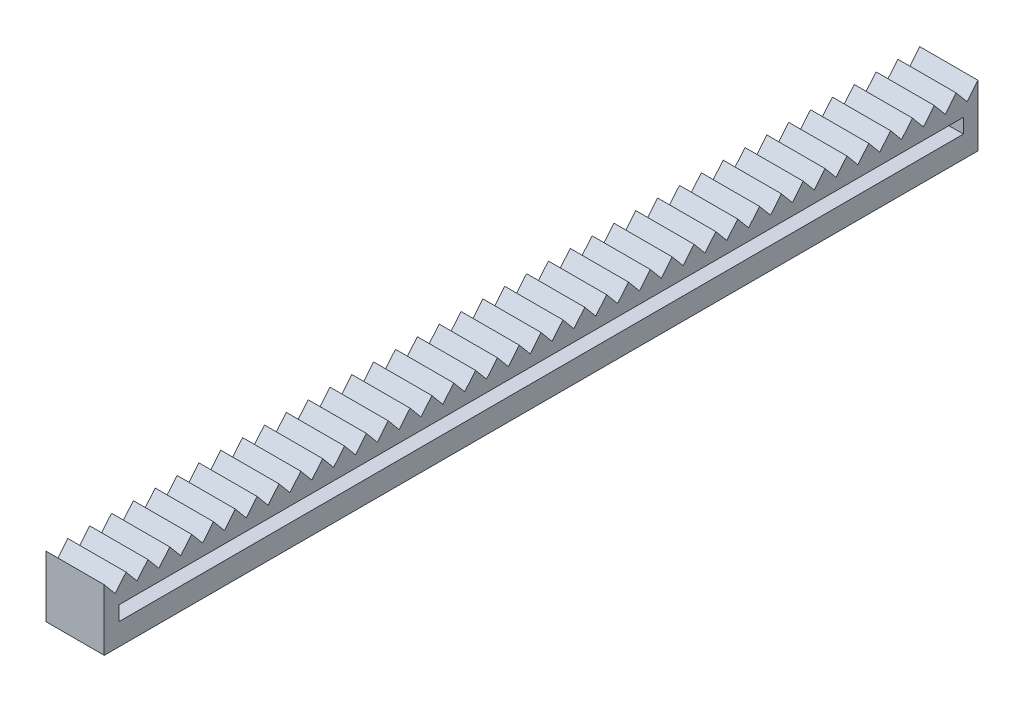
from build123d import *

# Parameters (mm, degrees)
SKETCH2_W                = 300
SKETCH2_H                = 21
BOSS_EXTRUDE2_DEPTH      = 10
BOSS_EXTRUDE2_DEPTH_BACK = 10
CUT_EXTRUDE1_DEPTH       = 20
LPATTERN1_COUNT          = 40
LPATTERN1_PITCH          = 7.5
SKETCH4_W                = 290
SKETCH4_H                = 5
CUT_EXTRUDE2_DEPTH       = 20


with BuildPart() as part:
    # Sketch2 → Boss-Extrude2 (new body, two sides)
    with BuildSketch(Plane(origin=(0, 0, 0), x_dir=(0, 0, -1), z_dir=(1, 0, 0))) as boss_extrude2_sk:
        with Locations((129.642857143, -19.5)):
            Rectangle(SKETCH2_W, SKETCH2_H)
    extrude(amount=BOSS_EXTRUDE2_DEPTH)
    extrude(boss_extrude2_sk.sketch, amount=-BOSS_EXTRUDE2_DEPTH_BACK)

    # Sketch3 → Cut-Extrude1 (cut)
    with BuildSketch(Plane(origin=(10, 0, 0), x_dir=(0, 0, -1), z_dir=(1, 0, 0))):
        Polygon((-20.357142857, -9), (-16.607142857, -13.5), (-12.857142857, -9), align=None)
    cut_extrude1 = extrude(amount=-CUT_EXTRUDE1_DEPTH, mode=Mode.SUBTRACT)

    # LPattern1: Cut-Extrude1 ×40
    with Locations(*[(0, 0, -i * LPATTERN1_PITCH) for i in range(1, LPATTERN1_COUNT)]):
        add(cut_extrude1, mode=Mode.SUBTRACT)

    # Sketch4 → Cut-Extrude2 (cut)
    with BuildSketch(Plane(origin=(10, 0, 0), x_dir=(0, 0, -1), z_dir=(1, 0, 0))):
        with Locations((129.642857143, -20)):
            Rectangle(SKETCH4_W, SKETCH4_H)
    extrude(amount=-CUT_EXTRUDE2_DEPTH, mode=Mode.SUBTRACT)


solid = part.part
